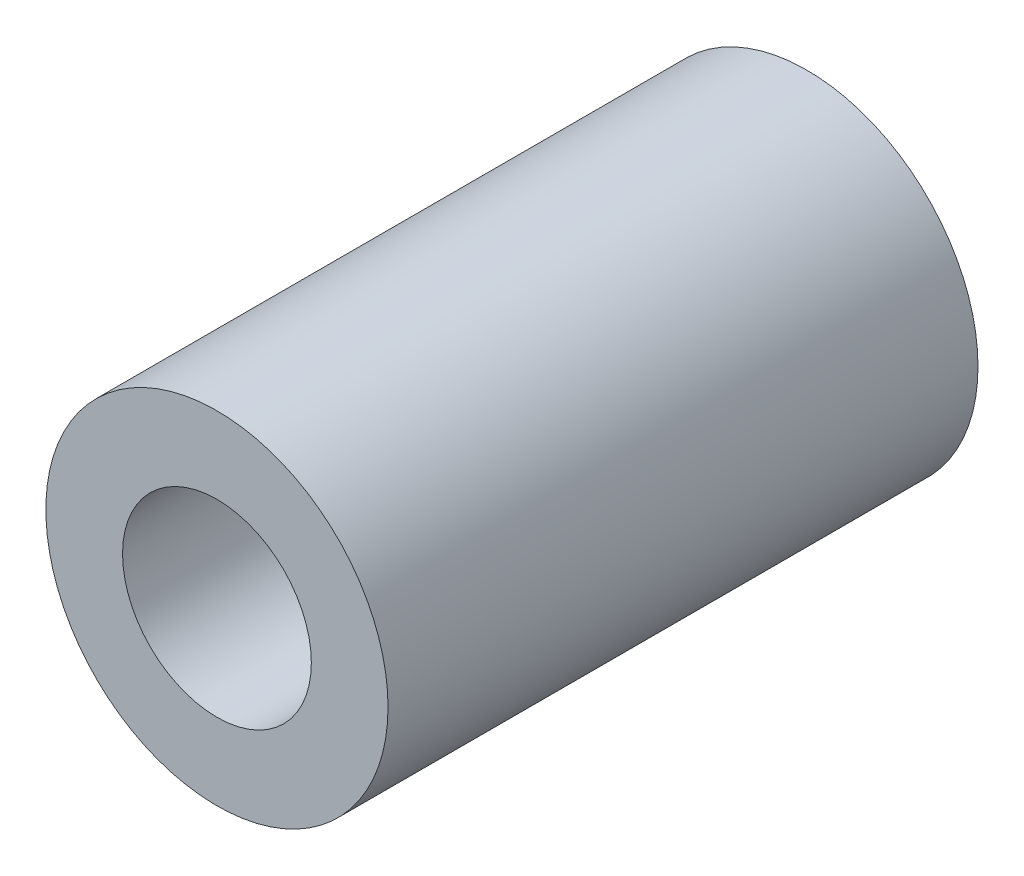
from build123d import *

# Parameters (mm, degrees)
SKETCH1_R           = 2.9
SKETCH1_R_2         = 1.6
BOSS_EXTRUDE1_DEPTH = 10


with BuildPart() as part:
    # Sketch1 → Boss-Extrude1 (new body)
    with BuildSketch(Plane.XY):
        Circle(SKETCH1_R)
        Circle(SKETCH1_R_2, mode=Mode.SUBTRACT)
    extrude(amount=BOSS_EXTRUDE1_DEPTH)


solid = part.part
